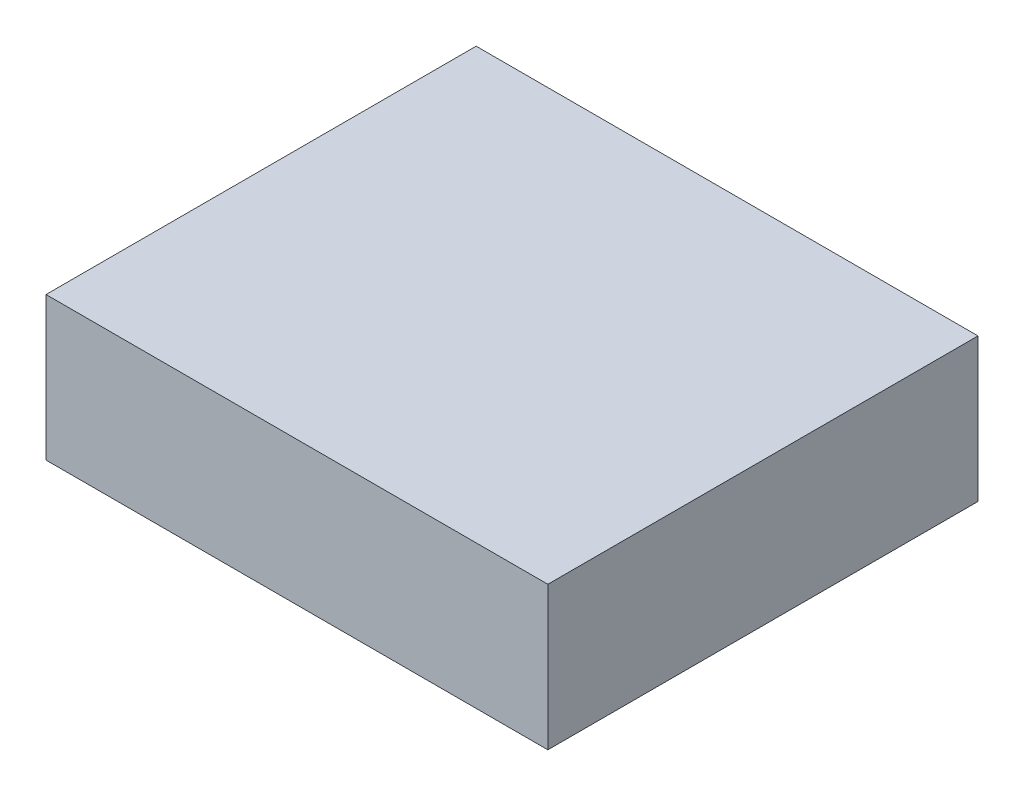
from build123d import *

# Parameters (mm, degrees)
SKETCH1_W           = 355.6
SKETCH1_H           = 304.8
BOSS_EXTRUDE1_DEPTH = 101.6


with BuildPart() as part:
    # Sketch1 → Boss-Extrude1 (new body)
    with BuildSketch(Plane(origin=(0, 0, 0), x_dir=(1, 0, 0), z_dir=(0, 1, 0))):
        Rectangle(SKETCH1_W, SKETCH1_H)
    extrude(amount=BOSS_EXTRUDE1_DEPTH)


solid = part.part
